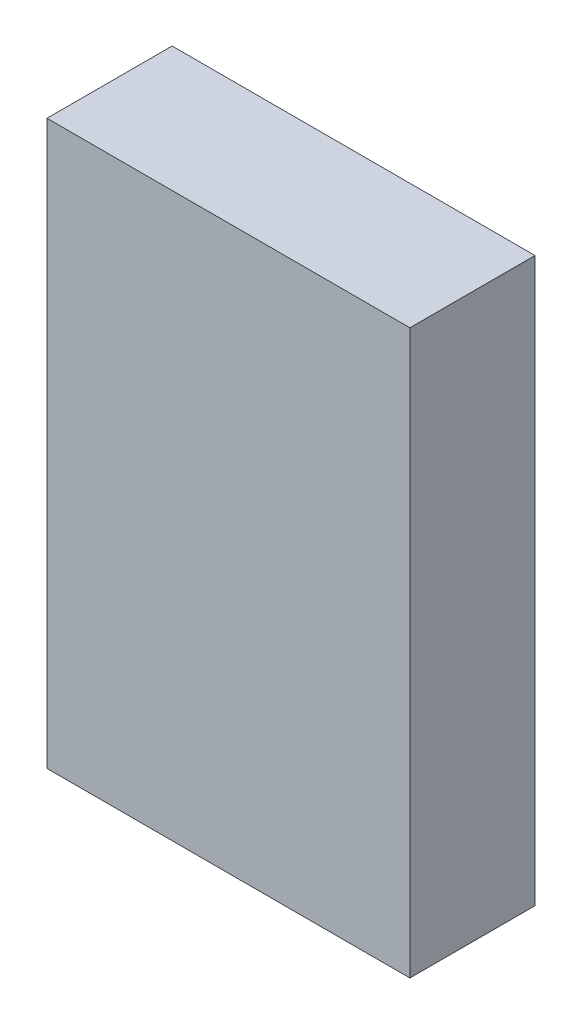
from build123d import *

# Parameters (mm, degrees)
SKETCH1_W           = 58
SKETCH1_H           = 90
BOSS_EXTRUDE1_DEPTH = 20


with BuildPart() as part:
    # Sketch1 → Boss-Extrude1 (new body)
    with BuildSketch(Plane.XY):
        Rectangle(SKETCH1_W, SKETCH1_H)
    extrude(amount=BOSS_EXTRUDE1_DEPTH)


solid = part.part
